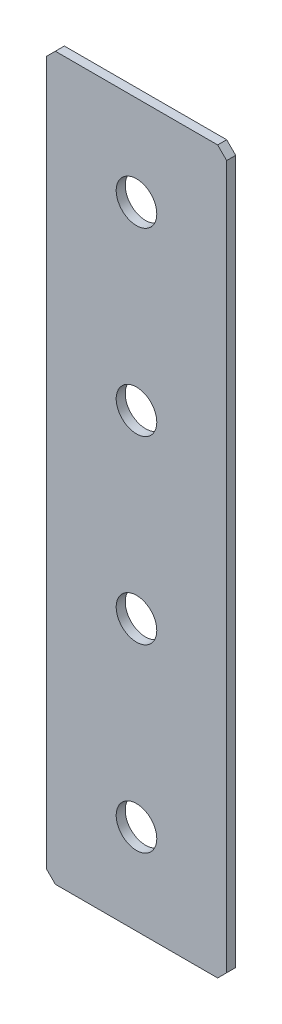
from build123d import *

# Parameters (mm, degrees)
SKETCH_1_W        = 40
SKETCH_1_H        = 160
EXTRUDE_1_DEPTH   = 2
CHAMFER_1_SIZE    = 2
HOLE_WIZARD_M81_D = 9


with BuildPart() as part:
    # Эскиз1 → Бобышка-Вытянуть1 (new body)
    with BuildSketch(Plane.XY):
        Rectangle(SKETCH_1_W, SKETCH_1_H)
    extrude(amount=EXTRUDE_1_DEPTH)

    # Фаска1
    chamfer_1_edges = [part.edges().sort_by_distance(p)[0] for p in [
        (20, -80, 1),
        (-20, -80, 1),
        (-20, 80, 1),
        (20, 80, 1),
    ]]
    chamfer(chamfer_1_edges, length=CHAMFER_1_SIZE)

    # Отверстие с зазором M81 (through all)
    with Locations(Plane.XY.offset(2)):
        with Locations((0, -60), (0, 60), (0, 20), (0, -20)):
            Hole(HOLE_WIZARD_M81_D / 2)


solid = part.part
